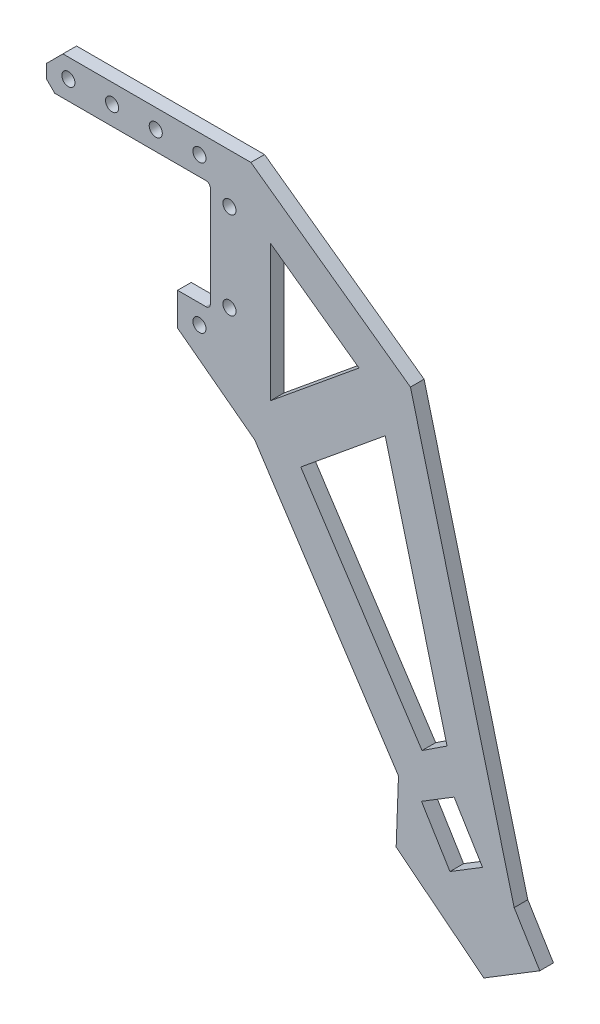
from build123d import *

# Parameters (mm, degrees)
ESQUISSE1_W             = 6
ESQUISSE1_H             = 6
BOSS_EXTRU_1_DEPTH      = 2.5
D_GAGEMENT_M21_D        = 2.4
CHANFREIN1_SIZE         = 1.5
CHANFREIN2_SIZE         = 3
CONG_3_R                = 0.8
ENL_V_MAT_EXTRU_1_REACH = 4.5


with BuildPart() as part:
    # Esquisse1 → Boss.-Extru.1 (new body)
    with BuildSketch(Plane.XY):
        Polygon((19.677471167, 17), (48.900602827, -4.024), (67.901253291, -77.094002614), (72.595795313, -84.772627178), (62.357629227, -91.032016541), (46.285412403, -78.306693506), (46.71123265, -66.806693506), (20.391821523, -26.665834049), align=None)
        Polygon((51.023072953, -60.616622474), (28.816069815, -26.747772307), (44.278044238, -14.062058021), (55.602935243, -57.613715208), align=None, mode=Mode.SUBTRACT)
        Polygon((39.485073144, -5.706221012), (23.25, 5.973778988), (23.25, -19.026221012), align=None, mode=Mode.SUBTRACT)
        Polygon((12.25, 17), (12.25, 10), (12.25, -10), (12.25, -16), (6.25, -16), (20.391821523, -26.665834049), (19.677471167, 17), align=None)
        with Locations((9.25, -13)):
            Rectangle(ESQUISSE1_W, ESQUISSE1_H)
        Polygon((12.25, 17), (12.25, 10), (-12.25, 10), (-17.75, 10), (-17.75, 17), align=None)
    extrude(amount=BOSS_EXTRU_1_DEPTH)

    # Dégagement M21 (through all)
    with Locations(Plane.XY.offset(2.5)):
        with Locations((-13.75, 13.5), (-5.75, 13.5), (2.25, 13.5), (10.25, 13.5), (15.75, 8), (15.75, -8), (10.25, -13.5)):
            Hole(D_GAGEMENT_M21_D / 2)

    # Chanfrein1
    chanfrein1_edges = [part.edges().sort_by_distance(p)[0] for p in [
        (-17.75, 10, 1.25),
    ]]
    chamfer(chanfrein1_edges, length=CHANFREIN1_SIZE)

    # Chanfrein2
    chanfrein2_edges = [part.edges().sort_by_distance(p)[0] for p in [
        (-17.75, 17, 1.25),
    ]]
    chamfer(chanfrein2_edges, length=CHANFREIN2_SIZE)

    # Congé3
    cong_3_edges = [part.edges().sort_by_distance(p)[0] for p in [
        (12.25, -10, 1.25),
        (12.25, 10, 1.25),
    ]]
    fillet(cong_3_edges, radius=CONG_3_R)

    # Esquisse6 → Enlèv. mat.-Extru.1 (cut, up to next)
    with BuildSketch(Plane.XY.offset(2.5), mode=Mode.PRIVATE) as enl_v_mat_extru_1_sk1:
        Polygon((50.923621455, -68.720394376), (56.895885005, -65.069083914), (62.112042808, -73.600888985), (56.139779258, -77.252199447), align=None)
    enl_v_mat_extru_1_tool1 = extrude(enl_v_mat_extru_1_sk1.sketch, amount=-ENL_V_MAT_EXTRU_1_REACH, mode=Mode.PRIVATE) & part.part
    add(enl_v_mat_extru_1_tool1.solids().sort_by_distance((56.517832, -71.160642, 2.5))[0], mode=Mode.SUBTRACT)


solid = part.part
